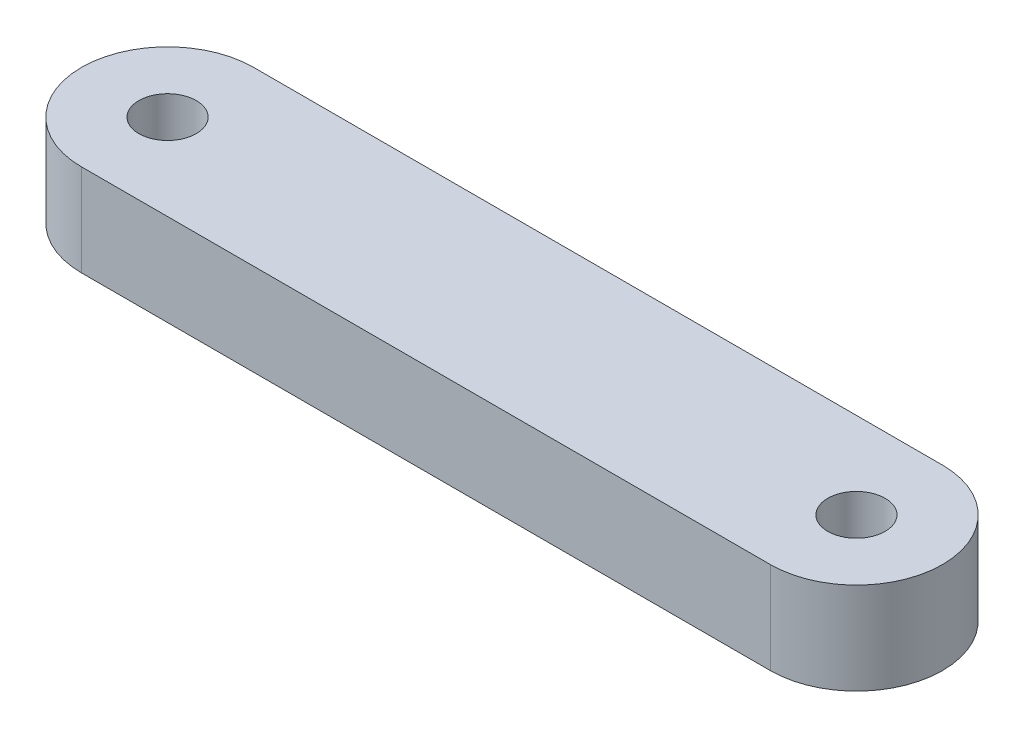
from build123d import *

# Parameters (mm, degrees)
SKETCH1_R           = 12.5
BOSS_EXTRUDE1_DEPTH = 40


with BuildPart() as part:
    # Sketch1 → Boss-Extrude1 (new body)
    with BuildSketch(Plane(origin=(0, 0, 0), x_dir=(1, 0, 0), z_dir=(0, 1, 0))):
        with BuildLine():
            Line((0, 37.5), (300, 37.5))
            ThreePointArc((300, 37.5), (337.5, 0), (300, -37.5))
            Line((300, -37.5), (0, -37.5))
            ThreePointArc((0, -37.5), (-37.5, 0), (0, 37.5))
        make_face()
        Circle(SKETCH1_R, mode=Mode.SUBTRACT)
        with Locations((300, 0)):
            Circle(SKETCH1_R, mode=Mode.SUBTRACT)
    extrude(amount=BOSS_EXTRUDE1_DEPTH)


solid = part.part
